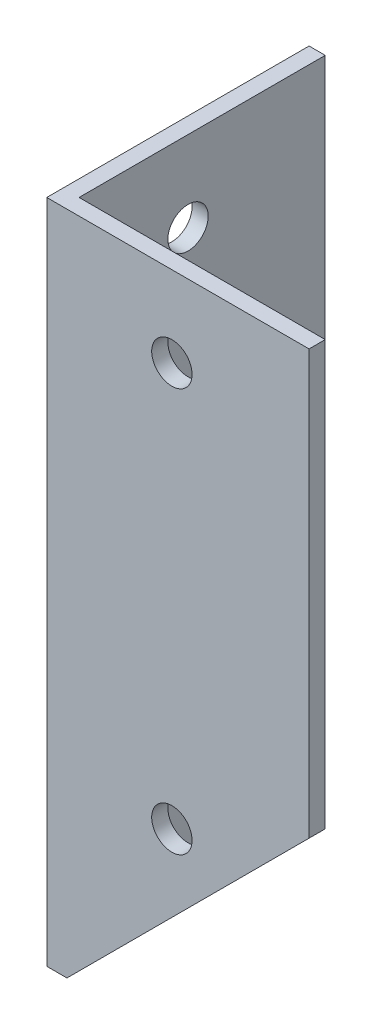
from build123d import *

# Parameters (mm, degrees)
EXTRUDE_1_DEPTH     = 165
SKETCH_2_R          = 5
CUT_EXTRUDE_1_DEPTH = 10
SKETCH_3_R          = 5
CUT_EXTRUDE_2_DEPTH = 10
CUT_EXTRUDE_3_DEPTH = 66


with BuildPart() as part:
    # Эскиз1 → Вытянуть-Тонкостенный1 (new body)
    with BuildSketch(Plane(origin=(0, 0, 0), x_dir=(1, 0, 0), z_dir=(0, 1, 0))):
        Polygon((0, 65), (0, 0), (65, 0), (65, 4), (4, 4), (4, 65), align=None)
    extrude(amount=EXTRUDE_1_DEPTH)

    # Эскиз2 → Вырез-Вытянуть1 (cut)
    with BuildSketch(Plane.XY):
        with Locations((31, 145)):
            Circle(SKETCH_2_R)
        with Locations((31, 45)):
            Circle(SKETCH_2_R)
    extrude(amount=-CUT_EXTRUDE_1_DEPTH, mode=Mode.SUBTRACT)

    # Эскиз3 → Вырез-Вытянуть2 (cut)
    with BuildSketch(Plane.ZY):
        with Locations((-31, 145)):
            Circle(SKETCH_3_R)
        with Locations((-31, 45)):
            Circle(SKETCH_3_R)
        with Locations((-15, 10)):
            Circle(SKETCH_3_R)
        with Locations((-45, 10)):
            Circle(SKETCH_3_R)
    extrude(amount=-CUT_EXTRUDE_2_DEPTH, mode=Mode.SUBTRACT)

    # Эскиз4 → Вырез-Вытянуть3 (cut, through all)
    with BuildSketch(Plane.XY):
        Polygon((5, 0), (65, 60), (65, 0), align=None)
    extrude(amount=-CUT_EXTRUDE_3_DEPTH, mode=Mode.SUBTRACT)


solid = part.part
